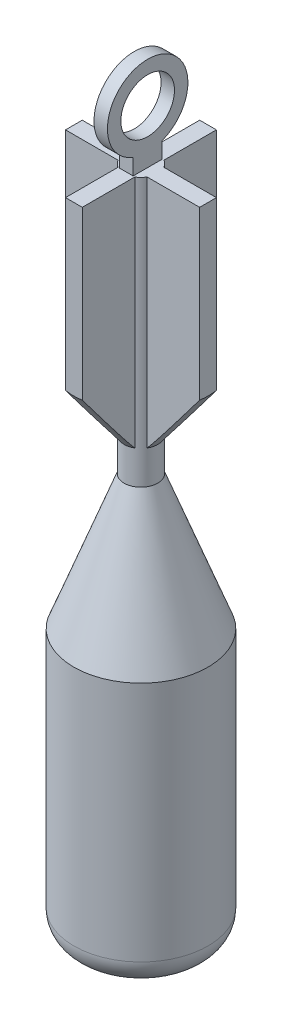
from build123d import *

# Parameters (mm, degrees)
SKETCH1_R           = 6.35
EXTRUDE1_DEPTH      = 25.4
FILLET1_R           = 2.54
EXTRUDE2_DEPTH      = 22.225
SKETCH9_R           = 2.54
EXTRUDE3_DEPTH      = 0.635
EXTRUDE3_DEPTH_BACK = 0.635


with BuildPart() as part:
    # Sketch1 → Extrude1 (new body)
    with BuildSketch(Plane(origin=(0, 0, 0), x_dir=(1, 0, 0), z_dir=(0, 1, 0))):
        Circle(SKETCH1_R)
    extrude(amount=EXTRUDE1_DEPTH)

    # Fillet1
    fillet1_edges = [part.edges().sort_by_distance(p)[0] for p in [
        (-6.35, 0, 0),
    ]]
    fillet(fillet1_edges, radius=FILLET1_R)

    # Sketch2 → Revolve1 (revolve)
    with BuildSketch(Plane(origin=(0, 0, 0), x_dir=(0, 0, -1), z_dir=(1, 0, 0))):
        Polygon((-6.35, 25.4), (0, 25.4), (0, 63.5), (-1.5875, 63.5), (-1.5875, 38.1), align=None)
    revolve(axis=Axis((0, 66.595768823, 0), (0, -1, 0)))

    # Sketch3 → Extrude2 (add)
    with BuildSketch(Plane(origin=(0, 63.5, 0), x_dir=(-1, 0, 0), z_dir=(0, 1, 0))):
        Polygon((0.79375, -0.79375), (0.79375, -6.35), (-0.79375, -6.35), (-0.79375, -0.79375), (-6.35, -0.79375), (-6.35, 0.79375), (-0.79375, 0.79375), (-0.79375, 6.35), (0.79375, 6.35), (0.79375, 0.79375), (6.35, 0.79375), (6.35, -0.79375), align=None)
    extrude(amount=-EXTRUDE2_DEPTH)

    # Sketch7 → Cut-Revolve5 (revolve, cut)
    with BuildSketch(Plane(origin=(0, 0, 0), x_dir=(0, 0, -1), z_dir=(1, 0, 0))):
        Polygon((7.438341529, 49.076122039), (1.5875, 41.275), (7.438341529, 41.275), align=None)
    revolve(axis=Axis((0, 0, 0), (0, 1, 0)), mode=Mode.SUBTRACT)

    # Sketch9 → Extrude3 (add, two sides)
    with BuildSketch(Plane(origin=(0, 0, 0), x_dir=(0, 0, -1), z_dir=(1, 0, 0))) as extrude3_sk:
        with BuildLine():
            Line((-1.374815329, 63.5), (-1.374815329, 65.024))
            ThreePointArc((-1.374815329, 65.024), (0, 72.387305899), (1.374815329, 65.024))
            Line((1.374815329, 65.024), (1.374815329, 63.5))
            Line((1.374815329, 63.5), (-1.374815329, 63.5))
        make_face()
        with Locations((0, 68.577305899)):
            Circle(SKETCH9_R, mode=Mode.SUBTRACT)
    extrude(amount=EXTRUDE3_DEPTH)
    extrude(extrude3_sk.sketch, amount=-EXTRUDE3_DEPTH_BACK)


solid = part.part
